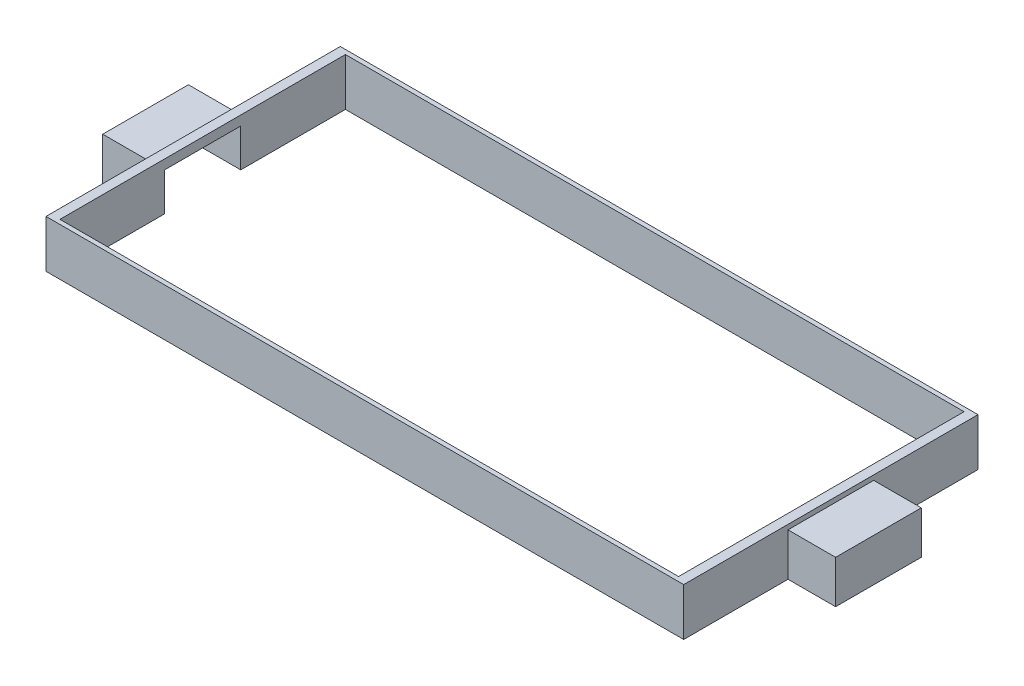
from build123d import *

# Parameters (mm, degrees)
SKETCH_1_W               = 6.7
SKETCH_1_H               = 3.092307692
SKETCH_1_W_2             = 6.5
SKETCH_1_H_2             = 3
EXTRUDE_1_DEPTH          = 0.5
SKETCH_3_W               = 0.8
SKETCH_3_H               = 0.4
CUT_EXTRUDE_1_DEPTH      = 1
CUT_EXTRUDE_1_DEPTH_BACK = 7.7
SKETCH_8_W               = 0.9
SKETCH_8_H               = 0.45
EXTRUDE_4_DEPTH          = 0.5
SKETCH_9_W               = 0.8
SKETCH_9_H               = 0.4
CUT_EXTRUDE_2_DEPTH      = 0.45


with BuildPart() as part:
    # 草圖1 → 填料-伸長1 (new body)
    with BuildSketch(Plane(origin=(0, 0, 0), x_dir=(1, 0, 0), z_dir=(0, 1, 0))):
        Rectangle(SKETCH_1_W, SKETCH_1_H)
        Rectangle(SKETCH_1_W_2, SKETCH_1_H_2, mode=Mode.SUBTRACT)
    extrude(amount=EXTRUDE_1_DEPTH)

    # 草圖3 → 除料-伸長1 (cut, two sides)
    with BuildSketch(Plane.ZY.offset(3.35)) as cut_extrude_1_sk:
        with Locations((0, 0.2)):
            Rectangle(SKETCH_3_W, SKETCH_3_H)
    extrude(amount=CUT_EXTRUDE_1_DEPTH, mode=Mode.SUBTRACT)
    extrude(cut_extrude_1_sk.sketch, amount=-CUT_EXTRUDE_1_DEPTH_BACK, mode=Mode.SUBTRACT)

    # 草圖8 → 填料-伸長4 (add)
    with BuildSketch(Plane.ZY.offset(3.35)):
        with Locations((0, 0.225)):
            Rectangle(SKETCH_8_W, SKETCH_8_H)
    extrude_4 = extrude(amount=EXTRUDE_4_DEPTH)

    # 草圖9 → 除料-伸長2 (cut)
    with BuildSketch(Plane(origin=(-3.35, 0, 0), x_dir=(0, 0, -1), z_dir=(1, 0, 0))):
        with Locations((0, 0.2)):
            Rectangle(SKETCH_9_W, SKETCH_9_H)
    cut_extrude_2 = extrude(amount=-CUT_EXTRUDE_2_DEPTH, mode=Mode.SUBTRACT)

    # 鏡射7: 填料-伸長4, 除料-伸長2 across plane
    add(extrude_4.mirror(Plane(origin=(0, 0, 0), x_dir=(0, 0, 1), z_dir=(1, 0, 0))))
    add(cut_extrude_2.mirror(Plane(origin=(0, 0, 0), x_dir=(0, 0, 1), z_dir=(1, 0, 0))), mode=Mode.SUBTRACT)


solid = part.part
